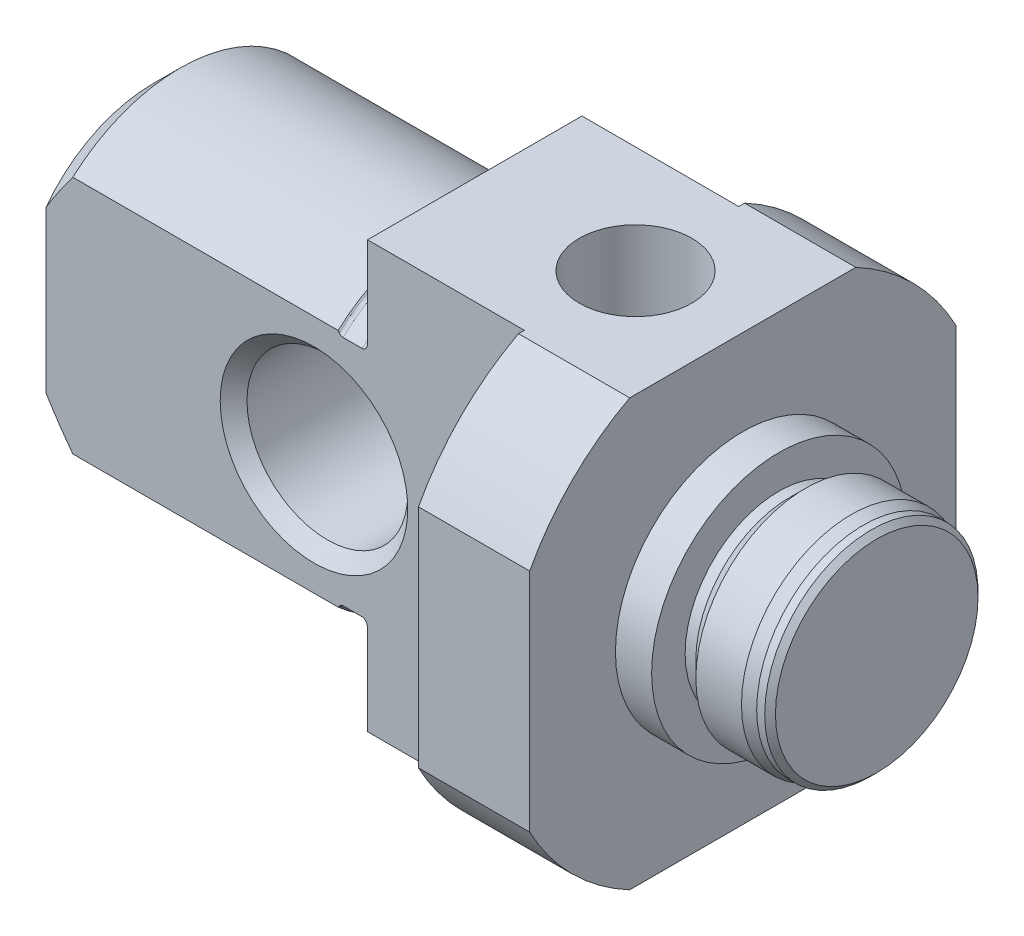
from build123d import *

# Parameters (mm, degrees)
O_L_DEPTH             = 17.85
CUT_EXTRUDE4_REACH    = 17
CUT_EXTRUDE2_REACH    = 13.95
SKETCH4_R             = 3
CHAMFER4_SIZE         = 0.5
M5_TAPPED_HOLE1_D     = 4.2
M5_TAPPED_HOLE1_DEPTH = 6
M5_TAPPED_HOLE1_TIP   = 1.212435565


with BuildPart() as part:
    # Sketch1 → Revolve1 (revolve)
    with BuildSketch(Plane.XY):
        with BuildLine():
            Line((-22, 0), (-22, 5))
            Line((-22, 5), (-21, 6))
            Line((-21, 6), (-11.1, 6))
            Line((-11.1, 6), (-11.058578644, 5.958578644))
            ThreePointArc((-11.058578644, 5.958578644), (-10.993693974, 5.915224093), (-10.917157288, 5.9))
            Line((-10.917157288, 5.9), (-10.2, 5.9))
            ThreePointArc((-10.2, 5.9), (-10.058578644, 5.958578644), (-10, 6.1))
            Line((-10, 6.1), (-10, 9))
            Line((-10, 9), (0, 9))
            Line((0, 9), (0, 4.75))
            Line((0, 4.75), (1.35, 4.75))
            Line((1.35, 4.75), (1.35, 3.5))
            Line((1.35, 3.5), (1.75, 3.5))
            Line((1.75, 3.5), (2.35, 4.1))
            Line((2.35, 4.1), (4.052153903, 4.1))
            Line((4.052153903, 4.1), (4.5, 3.98))
            Line((4.5, 3.98), (4.8, 3.98))
            Line((4.8, 3.98), (5, 3.78))
            Line((5, 3.78), (5, 0))
            Line((5, 0), (-22, 0))
        make_face()
    revolve(axis=Axis((0, 0, 0), (1, 0, 0)))

    # Sketch3 → O-L (cut)
    with BuildSketch(Plane.ZY.offset(22)):
        with BuildLine():
            Line((-4, 8.062257748), (-4, -8.062257748))
            ThreePointArc((-4, -8.062257748), (-9, 0), (-4, 8.062257748))
        make_face()
        with BuildLine():
            Line((4, 8.062257748), (4, -8.062257748))
            ThreePointArc((4, -8.062257748), (9, 0), (4, 8.062257748))
        make_face()
    extrude(amount=-O_L_DEPTH, mode=Mode.SUBTRACT)

    # Sketch6 → Cut-Extrude4 (cut, up to next)
    with BuildSketch(Plane.ZY.offset(10), mode=Mode.PRIVATE) as cut_extrude4_sk1:
        with BuildLine():
            Line((-4.218708333, 7.95), (4.218708333, 7.95))
            ThreePointArc((4.218708333, 7.95), (0, 9), (-4.218708333, 7.95))
        make_face()
    cut_extrude4_tool1 = extrude(cut_extrude4_sk1.sketch, amount=-CUT_EXTRUDE4_REACH, mode=Mode.PRIVATE) & part.part
    add(cut_extrude4_tool1.solids().sort_by_distance((-10, 8.372173, 0))[0], mode=Mode.SUBTRACT)
    # Sketch6 → Cut-Extrude4 (cut, up to next)
    with BuildSketch(Plane.ZY.offset(10), mode=Mode.PRIVATE) as cut_extrude4_sk2:
        with BuildLine():
            Line((7.95, 4.218708333), (7.95, -4.218708333))
            ThreePointArc((7.95, -4.218708333), (9, 0), (7.95, 4.218708333))
        make_face()
    cut_extrude4_tool2 = extrude(cut_extrude4_sk2.sketch, amount=-CUT_EXTRUDE4_REACH, mode=Mode.PRIVATE) & part.part
    add(cut_extrude4_tool2.solids().sort_by_distance((-10, 0, 8.372173))[0], mode=Mode.SUBTRACT)
    # Sketch6 → Cut-Extrude4 (cut, up to next)
    with BuildSketch(Plane.ZY.offset(10), mode=Mode.PRIVATE) as cut_extrude4_sk3:
        with BuildLine():
            Line((4.218708333, -7.95), (-4.218708333, -7.95))
            ThreePointArc((-4.218708333, -7.95), (0, -9), (4.218708333, -7.95))
        make_face()
    cut_extrude4_tool3 = extrude(cut_extrude4_sk3.sketch, amount=-CUT_EXTRUDE4_REACH, mode=Mode.PRIVATE) & part.part
    add(cut_extrude4_tool3.solids().sort_by_distance((-10, -8.372173, 0))[0], mode=Mode.SUBTRACT)
    # Sketch6 → Cut-Extrude4 (cut, up to next)
    with BuildSketch(Plane.ZY.offset(10), mode=Mode.PRIVATE) as cut_extrude4_sk4:
        with BuildLine():
            Line((-7.95, -4.218708333), (-7.95, 4.218708333))
            ThreePointArc((-7.95, 4.218708333), (-9, 0), (-7.95, -4.218708333))
        make_face()
    cut_extrude4_tool4 = extrude(cut_extrude4_sk4.sketch, amount=-CUT_EXTRUDE4_REACH, mode=Mode.PRIVATE) & part.part
    add(cut_extrude4_tool4.solids().sort_by_distance((-10, 0, -8.372173))[0], mode=Mode.SUBTRACT)

    # Sketch4 → Cut-Extrude2 (cut, up to next)
    with BuildSketch(Plane.XY.offset(4), mode=Mode.PRIVATE) as cut_extrude2_sk1:
        with Locations((-12, 0)):
            Circle(SKETCH4_R)
    cut_extrude2_tool1 = extrude(cut_extrude2_sk1.sketch, amount=-CUT_EXTRUDE2_REACH, mode=Mode.PRIVATE) & part.part
    add(cut_extrude2_tool1.solids().sort_by_distance((-12, 0, 4))[0], mode=Mode.SUBTRACT)

    # Chamfer4
    chamfer4_edges = [part.edges().sort_by_distance(p)[0] for p in [
        (-15, 0, 4),
        (-15, 0, -4),
    ]]
    chamfer(chamfer4_edges, length=CHAMFER4_SIZE)

    # M5 Tapped Hole1
    with Locations(Plane(origin=(0, 7.95, 0), x_dir=(1, 0, 0), z_dir=(0, 1, 0))):
        with Locations((-4, 0)):
            Hole(M5_TAPPED_HOLE1_D / 2, depth=M5_TAPPED_HOLE1_DEPTH)
            with Locations((0, 0, -(M5_TAPPED_HOLE1_DEPTH + M5_TAPPED_HOLE1_TIP / 2))):  # 120° drill point
                Cone(0, M5_TAPPED_HOLE1_D / 2, M5_TAPPED_HOLE1_TIP, mode=Mode.SUBTRACT)


solid = part.part
